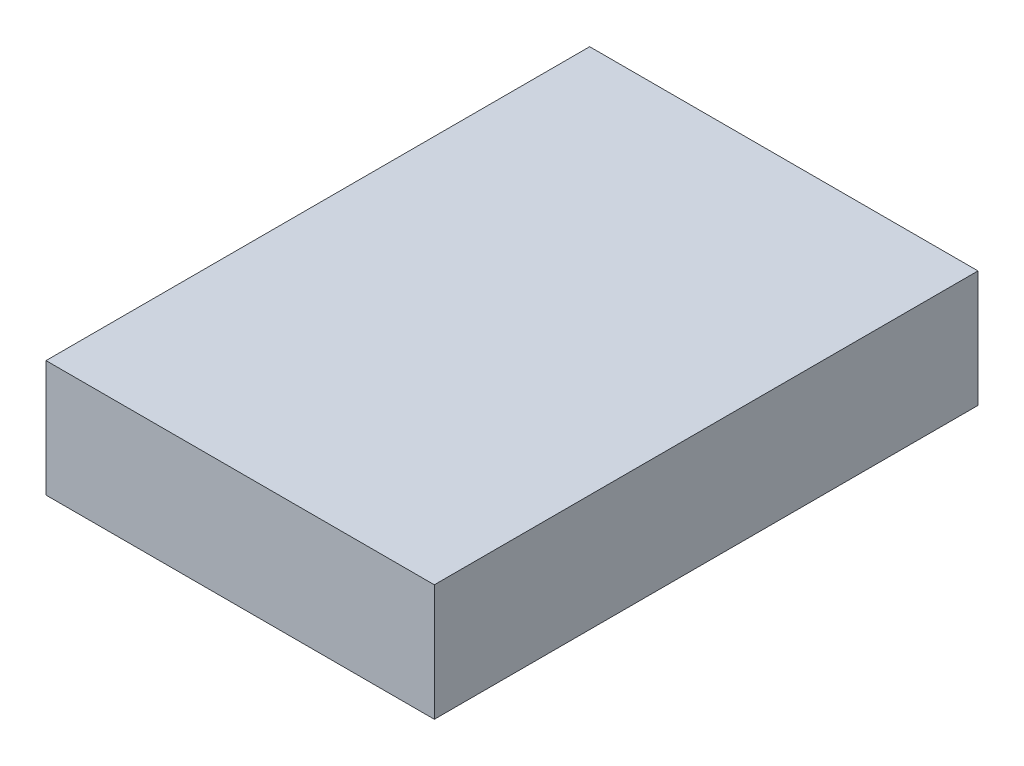
from build123d import *

# Parameters (mm, degrees)
SKETCH1_W           = 63.5
SKETCH1_H           = 88.9
BOSS_EXTRUDE1_DEPTH = 19.05


with BuildPart() as part:
    # Sketch1 → Boss-Extrude1 (new body)
    with BuildSketch(Plane(origin=(0, 0, 0), x_dir=(1, 0, 0), z_dir=(0, 1, 0))):
        with Locations((-37.747222222, -13.581944444)):
            Rectangle(SKETCH1_W, SKETCH1_H)
    extrude(amount=BOSS_EXTRUDE1_DEPTH)


solid = part.part
